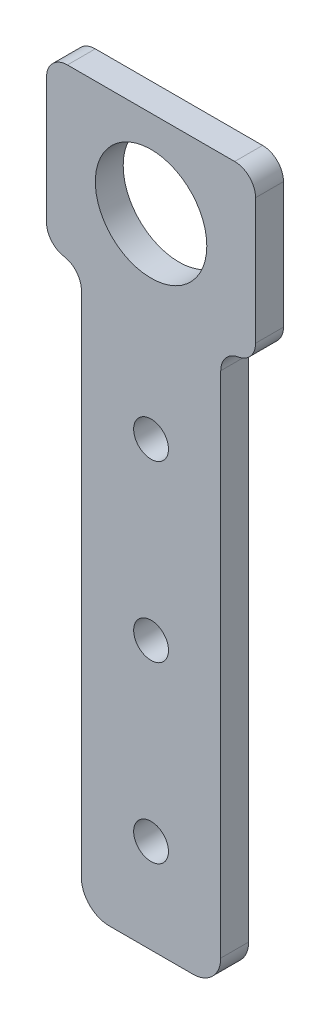
from build123d import *

# Parameters (mm, degrees)
SKETCH_1_W          = 20
SKETCH_1_H          = 30
SKETCH_1_R          = 1.5
EXTRUDE_1_DEPTH     = 4
SKETCH_2_W          = 30
SKETCH_2_H          = 4
EXTRUDE_2_DEPTH     = 24
FILLET_1_R          = 3
SKETCH_3_R          = 8
CUT_EXTRUDE_1_DEPTH = 24
FILLET_2_R          = 3
SKETCH_4_R          = 1.5
EXTRUDE_3_DEPTH     = 4
SKETCH_9_R          = 2.5
CUT_EXTRUDE_2_DEPTH = 5.0000001
SKETCH_11_W         = 20
SKETCH_11_H         = 50
EXTRUDE_5_DEPTH     = 4
SKETCH_13_R         = 2.5
CUT_EXTRUDE_3_DEPTH = 10
FILLET_4_R          = 4
FILLET_5_R          = 4


with BuildPart() as part:
    # 草图1 → 凸台-拉伸1 (new body)
    with BuildSketch(Plane.XY):
        Rectangle(SKETCH_1_W, SKETCH_1_H)
        with Locations((-5, 3)):
            Circle(SKETCH_1_R, mode=Mode.SUBTRACT)
        with Locations((5, 3)):
            Circle(SKETCH_1_R, mode=Mode.SUBTRACT)
        with Locations((-5, -7)):
            Circle(SKETCH_1_R, mode=Mode.SUBTRACT)
        with Locations((5, -7)):
            Circle(SKETCH_1_R, mode=Mode.SUBTRACT)
    extrude(amount=EXTRUDE_1_DEPTH)

    # 草图2 → 凸台-拉伸2 (add)
    with BuildSketch(Plane(origin=(0, 15, 0), x_dir=(1, 0, 0), z_dir=(0, 1, 0))):
        with Locations((0, -2)):
            Rectangle(SKETCH_2_W, SKETCH_2_H)
    extrude(amount=EXTRUDE_2_DEPTH)

    # 圆角1
    fillet_1_edges = [part.edges().sort_by_distance(p)[0] for p in [
        (-10, 15, 2),
        (10, 15, 2),
    ]]
    fillet(fillet_1_edges, radius=FILLET_1_R)

    # 草图3 → 切除-拉伸1 (cut)
    with BuildSketch(Plane.XY.offset(4)):
        with Locations((0, 26.5)):
            Circle(SKETCH_3_R)
    extrude(amount=-CUT_EXTRUDE_1_DEPTH, mode=Mode.SUBTRACT)

    # 圆角2
    fillet_2_edges = [part.edges().sort_by_distance(p)[0] for p in [
        (15, 15, 2),
        (15, 39, 2),
        (-15, 39, 2),
        (-15, 15, 2),
    ]]
    fillet(fillet_2_edges, radius=FILLET_2_R)

    # 草图4 → 凸台-拉伸3 (add)
    with BuildSketch(Plane.XY.offset(4)):
        with Locations((5, 3)):
            Circle(SKETCH_4_R)
        with Locations((5, -7)):
            Circle(SKETCH_4_R)
        with Locations((-5, 3)):
            Circle(SKETCH_4_R)
        with Locations((-5, -7)):
            Circle(SKETCH_4_R)
    extrude(amount=-EXTRUDE_3_DEPTH)

    # 草图9 → 切除-拉伸2 (cut, through all)
    with BuildSketch(Plane.XY.offset(4)):
        with Locations((0, -1.5)):
            Circle(SKETCH_9_R)
    extrude(amount=-CUT_EXTRUDE_2_DEPTH, mode=Mode.SUBTRACT)

    # 草图11 → 凸台-拉伸5 (add)
    with BuildSketch(Plane.XY.offset(4)):
        with Locations((0, -40)):
            Rectangle(SKETCH_11_W, SKETCH_11_H)
    extrude(amount=-EXTRUDE_5_DEPTH)

    # 草图13 → 切除-拉伸3 (cut)
    with BuildSketch(Plane.XY.offset(4)):
        with Locations((0, -26.5)):
            Circle(SKETCH_13_R)
        with Locations((0, -51.5)):
            Circle(SKETCH_13_R)
    extrude(amount=-CUT_EXTRUDE_3_DEPTH, mode=Mode.SUBTRACT)

    # 圆角4
    fillet_4_edges = [part.edges().sort_by_distance(p)[0] for p in [
        (10, -65, 2),
    ]]
    fillet(fillet_4_edges, radius=FILLET_4_R)

    # 圆角5
    fillet_5_edges = [part.edges().sort_by_distance(p)[0] for p in [
        (-10, -65, 2),
    ]]
    fillet(fillet_5_edges, radius=FILLET_5_R)


solid = part.part
